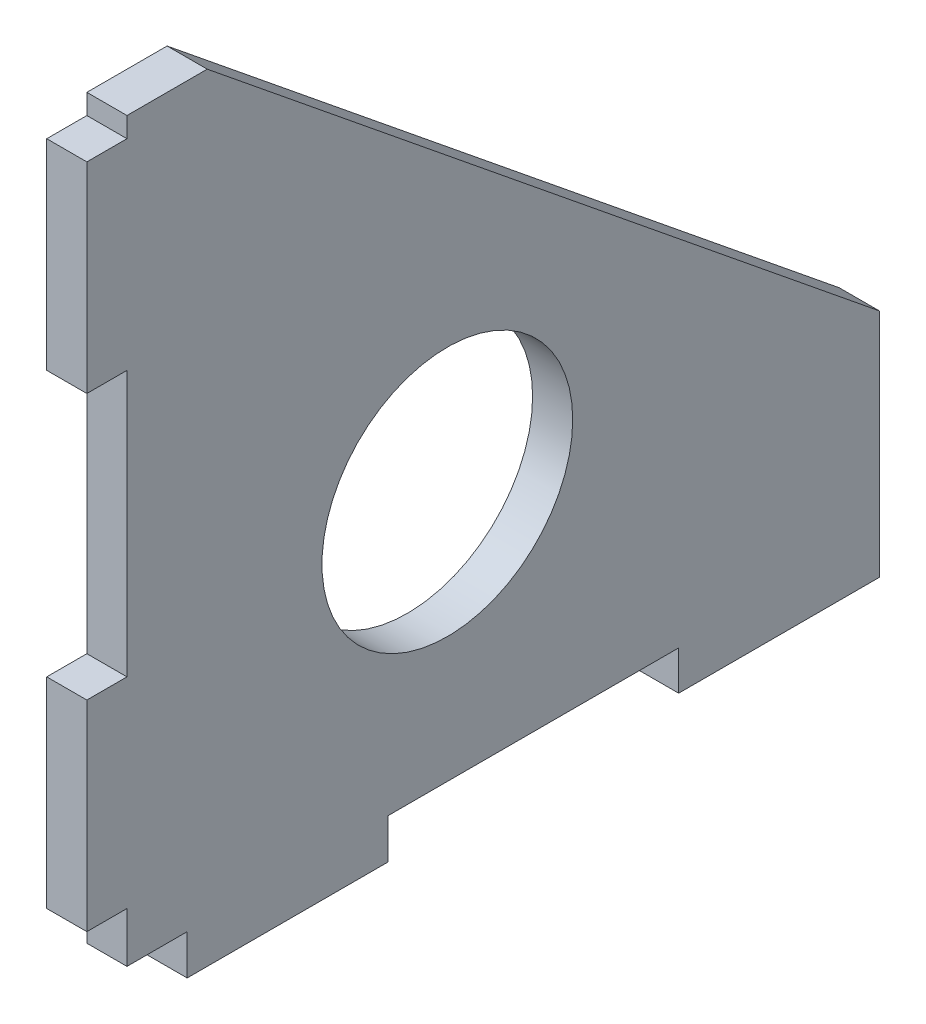
from build123d import *

# Parameters (mm, degrees)
SKETCH1_R           = 12.5
BOSS_EXTRUDE1_DEPTH = 4


with BuildPart() as part:
    # Sketch1 → Boss-Extrude1 (new body)
    with BuildSketch(Plane(origin=(0, 0, 0), x_dir=(0, 0, -1), z_dir=(1, 0, 0))):
        Polygon((-32.145071831, 34.052951323), (-32.145071831, 14.052951323), (-28.145071831, 14.052951323), (-28.145071831, -12.409790693), (-32.145071831, -12.409790693), (-32.145071831, -32.409790693), (-28.145071831, -32.409790693), (-28.145071831, -37.409790693), (-22.145071831, -37.409790693), (-22.145071831, -41.409790693), (-2.145071831, -41.409790693), (-2.145071831, -37.409790693), (26.854928169, -37.409790693), (26.854928169, -41.322671818), (46.854928169, -41.322671818), (46.854928169, -18.308632295), (-20.145071831, 36.057032999), (-28.145071831, 36.057032999), (-28.145071831, 34.052951323), align=None)
        with Locations((3.793770472, -12.409790693)):
            Circle(SKETCH1_R, mode=Mode.SUBTRACT)
    extrude(amount=BOSS_EXTRUDE1_DEPTH)


solid = part.part
